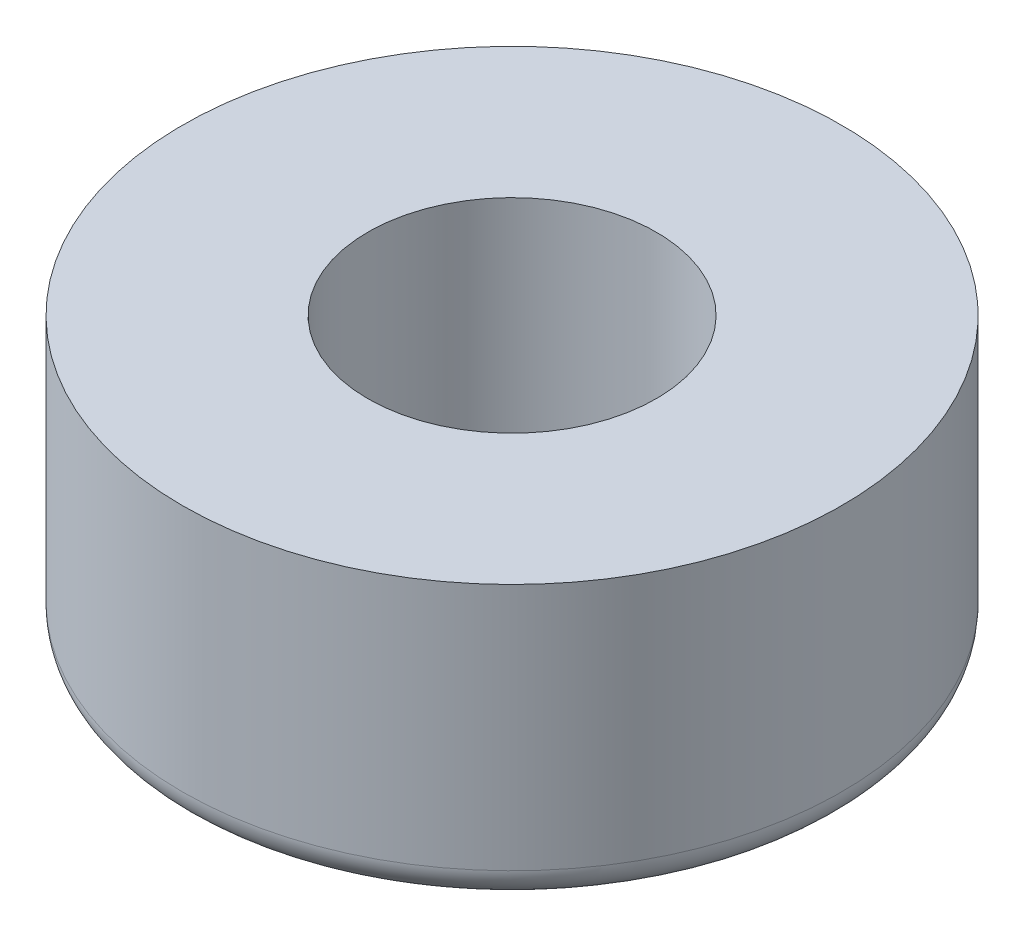
from build123d import *

# Parameters (mm, degrees)
SKETCH1_R           = 7.9375
SKETCH1_R_2         = 3.475000035
BOSS_EXTRUDE1_DEPTH = 6.731
FILLET1_R           = 0.76


with BuildPart() as part:
    # Sketch1 → Boss-Extrude1 (new body)
    with BuildSketch(Plane(origin=(0, 0, 0), x_dir=(1, 0, 0), z_dir=(0, 1, 0))):
        Circle(SKETCH1_R)
        Circle(SKETCH1_R_2, mode=Mode.SUBTRACT)
    extrude(amount=BOSS_EXTRUDE1_DEPTH)

    # Fillet1
    fillet1_edges = [part.edges().sort_by_distance(p)[0] for p in [
        (-7.9375, 0, 0),
    ]]
    fillet(fillet1_edges, radius=FILLET1_R)


solid = part.part
